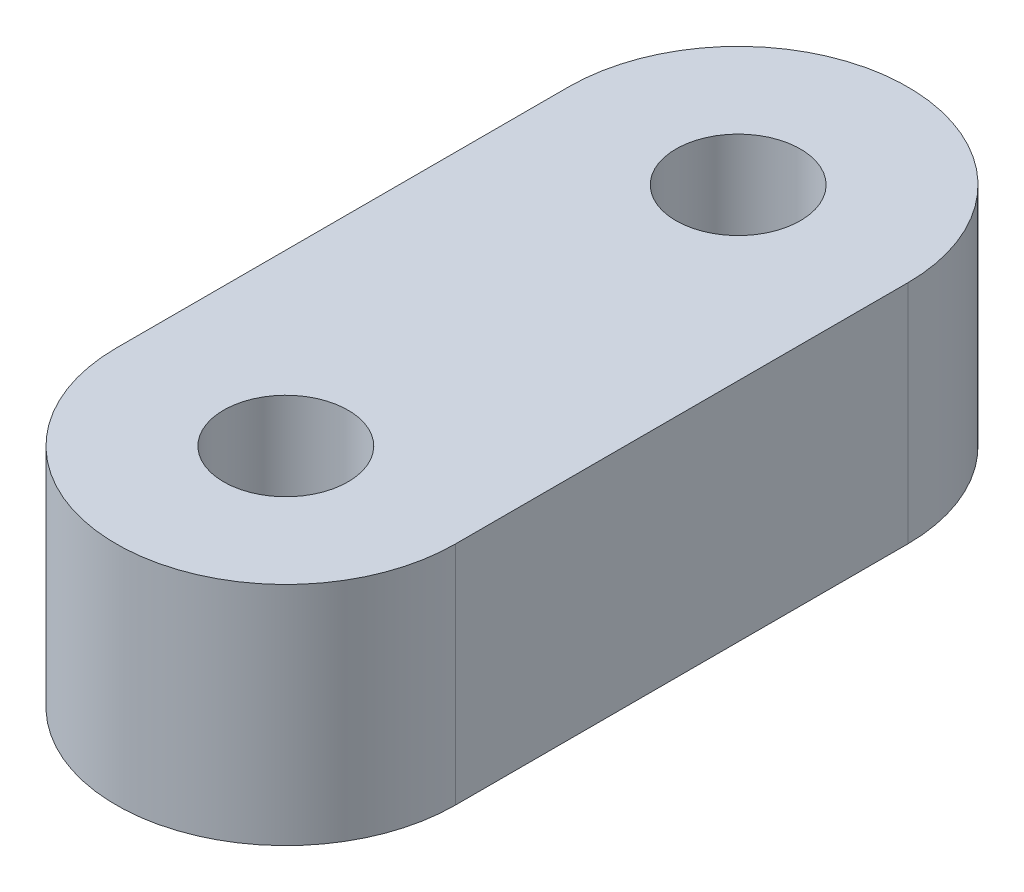
from build123d import *

# Parameters (mm, degrees)
SKETCH1_R           = 2.75
BOSS_EXTRUDE1_DEPTH = 10


with BuildPart() as part:
    # Sketch1 → Boss-Extrude1 (new body)
    with BuildSketch(Plane(origin=(0, 0, 0), x_dir=(1, 0, 0), z_dir=(0, 1, 0))):
        with BuildLine():
            Line((7.5, 20), (7.5, 0))
            ThreePointArc((7.5, 0), (0, -7.5), (-7.5, 0))
            Line((-7.5, 0), (-7.5, 20))
            ThreePointArc((-7.5, 20), (0, 27.5), (7.5, 20))
        make_face()
        with Locations((0, 20)):
            Circle(SKETCH1_R, mode=Mode.SUBTRACT)
        Circle(SKETCH1_R, mode=Mode.SUBTRACT)
    extrude(amount=BOSS_EXTRUDE1_DEPTH)


solid = part.part
